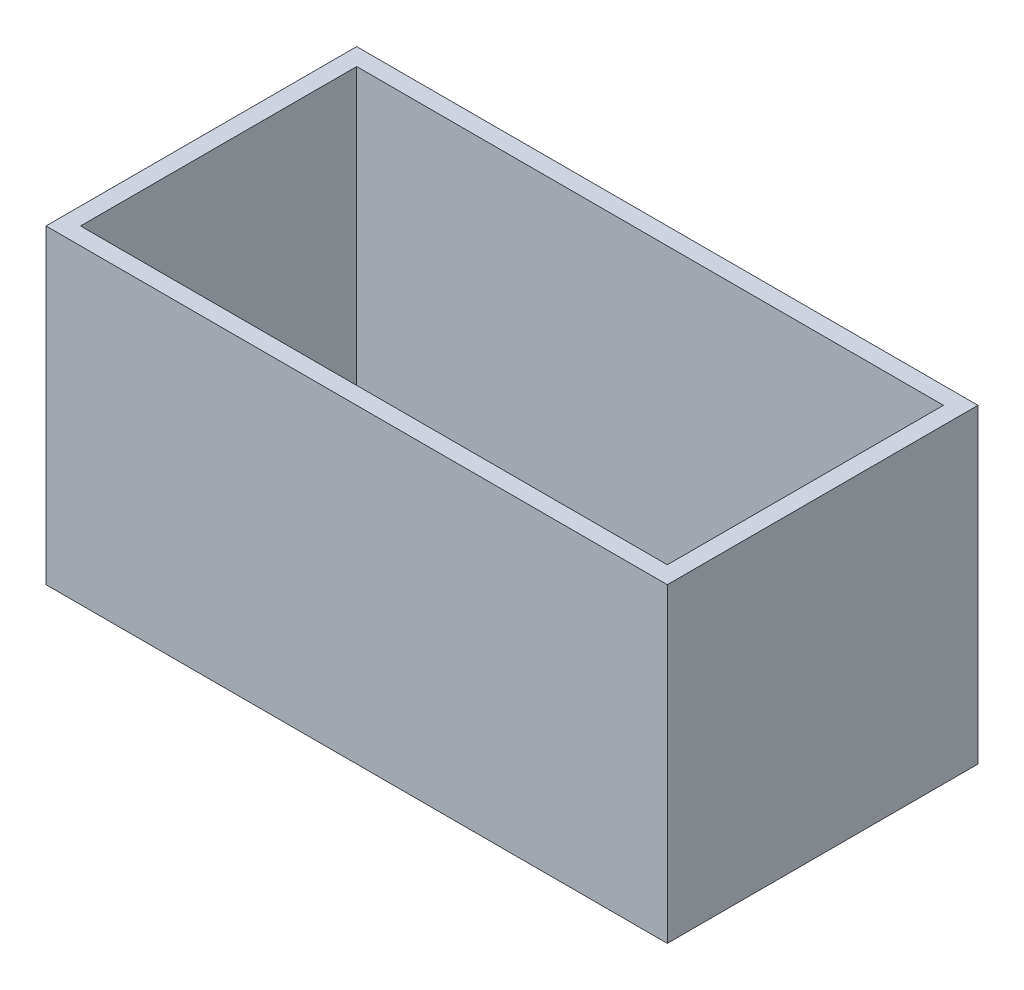
from build123d import *

# Parameters (mm, degrees)
SKETCH1_W           = 36
SKETCH1_H           = 18
BOSS_EXTRUDE1_DEPTH = 18
SHELL1_T            = -1


with BuildPart() as part:
    # Sketch1 → Boss-Extrude1 (new body)
    with BuildSketch(Plane(origin=(0, 0, 0), x_dir=(1, 0, 0), z_dir=(0, 1, 0))):
        Rectangle(SKETCH1_W, SKETCH1_H)
    extrude(amount=BOSS_EXTRUDE1_DEPTH)

    # Shell1
    shell1_openings = [part.faces().sort_by_distance(p)[0] for p in [
        (0, 18, 0),
    ]]
    offset(amount=SHELL1_T, openings=shell1_openings, kind=Kind.INTERSECTION)


solid = part.part
